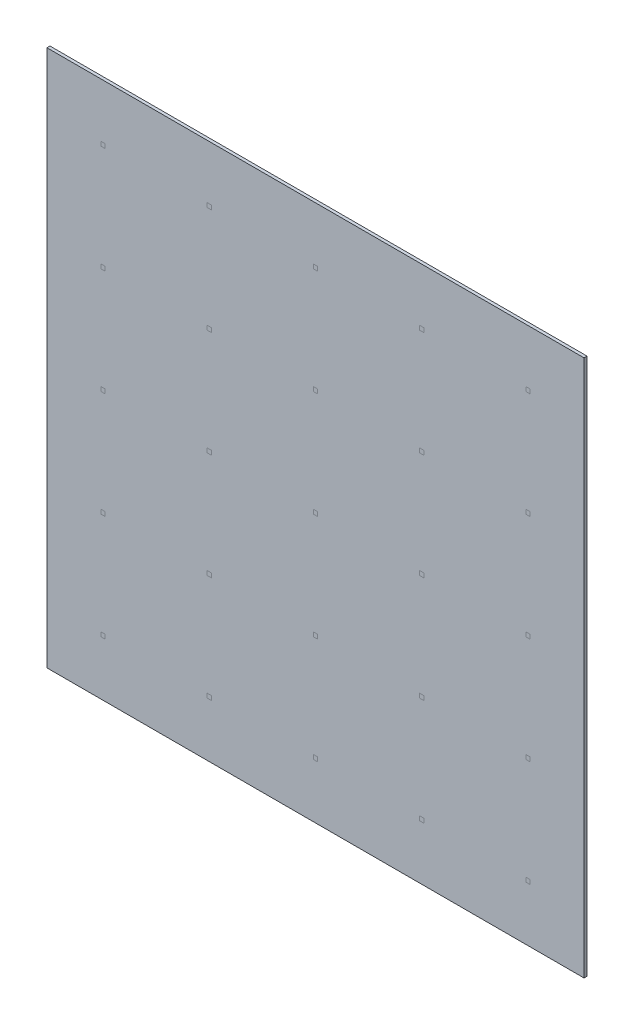
from build123d import *

# Parameters (mm, degrees)
SKETCH7_W           = 4.45
SKETCH7_H           = 4.45
BOSS_EXTRUDE1_DEPTH = 0.025


with BuildPart() as part:
    # Sketch7 → Boss-Extrude1 (new body)
    with BuildSketch(Plane.XY):
        with Locations((2.2, 2.2)):
            Rectangle(SKETCH7_W, SKETCH7_H)
    extrude(amount=BOSS_EXTRUDE1_DEPTH)


solid = part.part
